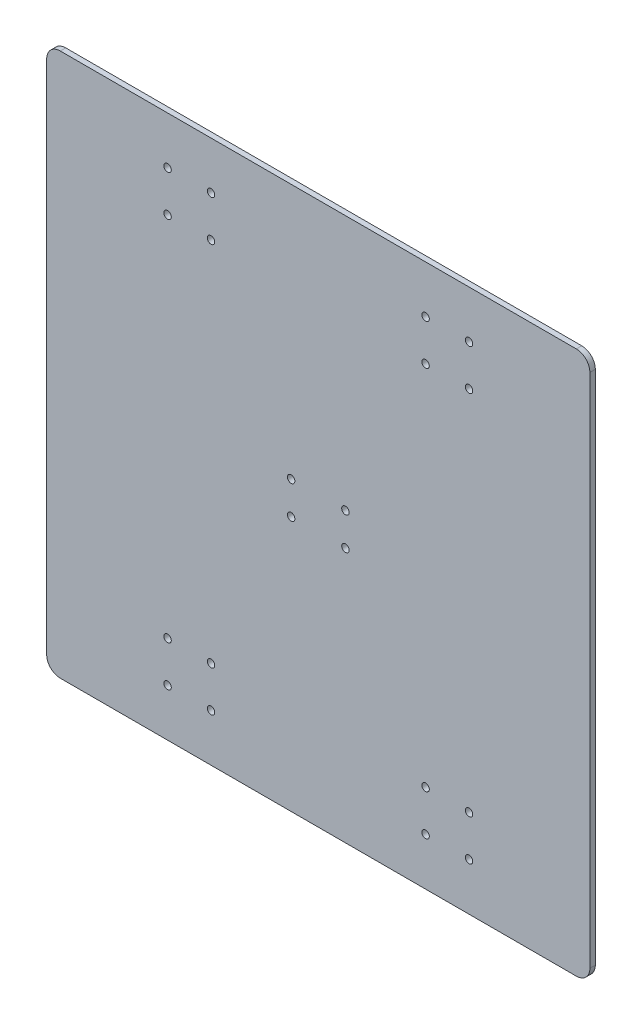
from build123d import *

# Parameters (mm, degrees)
SKETCH_1_W                  = 400
SKETCH_1_H                  = 400
EXTRUDE_1_DEPTH             = 4
HOLE_WIZARD_5_5_5_5_1_D     = 5.5
PATTERN_LINEAR_1_COUNT      = 2
PATTERN_LINEAR_1_PITCH      = 300
PATTERN_LINEAR_1_COUNT_DIR2 = 2
PATTERN_LINEAR_1_PITCH_DIR2 = 190
HOLE_WIZARD_5_5_5_5_2_D     = 5.5
FILLET_1_R                  = 10


with BuildPart() as part:
    # Эскиз1 → Бобышка-Вытянуть1 (new body)
    with BuildSketch(Plane.XY):
        Rectangle(SKETCH_1_W, SKETCH_1_H)
    extrude(amount=EXTRUDE_1_DEPTH)

    # Диаметр отверстия Ø5.5 (5.5)1 (through all)
    with Locations(Plane.XY.offset(4)):
        with Locations((79, 165), (79, 135), (111, 135), (111, 165)):
            hole_wizard_5_5_5_5_1 = Hole(HOLE_WIZARD_5_5_5_5_1_D / 2)

    # Линейный массив1: Hole Wizard 5.5 _5.5_1 2 × 2
    with Locations(*[(-j * PATTERN_LINEAR_1_PITCH_DIR2, -i * PATTERN_LINEAR_1_PITCH, 0) for i in range(PATTERN_LINEAR_1_COUNT) for j in range(PATTERN_LINEAR_1_COUNT_DIR2) if (i, j) != (0, 0)]):
        add(hole_wizard_5_5_5_5_1, mode=Mode.SUBTRACT)

    # Диаметр отверстия Ø5.5 (5.5)2 (through all)
    with Locations(Plane.XY.offset(4)):
        with Locations((20, 12), (-20, 12), (-20, -12), (20, -12)):
            Hole(HOLE_WIZARD_5_5_5_5_2_D / 2)

    # Скругление1
    fillet_1_edges = [part.edges().sort_by_distance(p)[0] for p in [
        (200, -200, 2),
        (-200, -200, 2),
        (-200, 200, 2),
        (200, 200, 2),
    ]]
    fillet(fillet_1_edges, radius=FILLET_1_R)


solid = part.part
